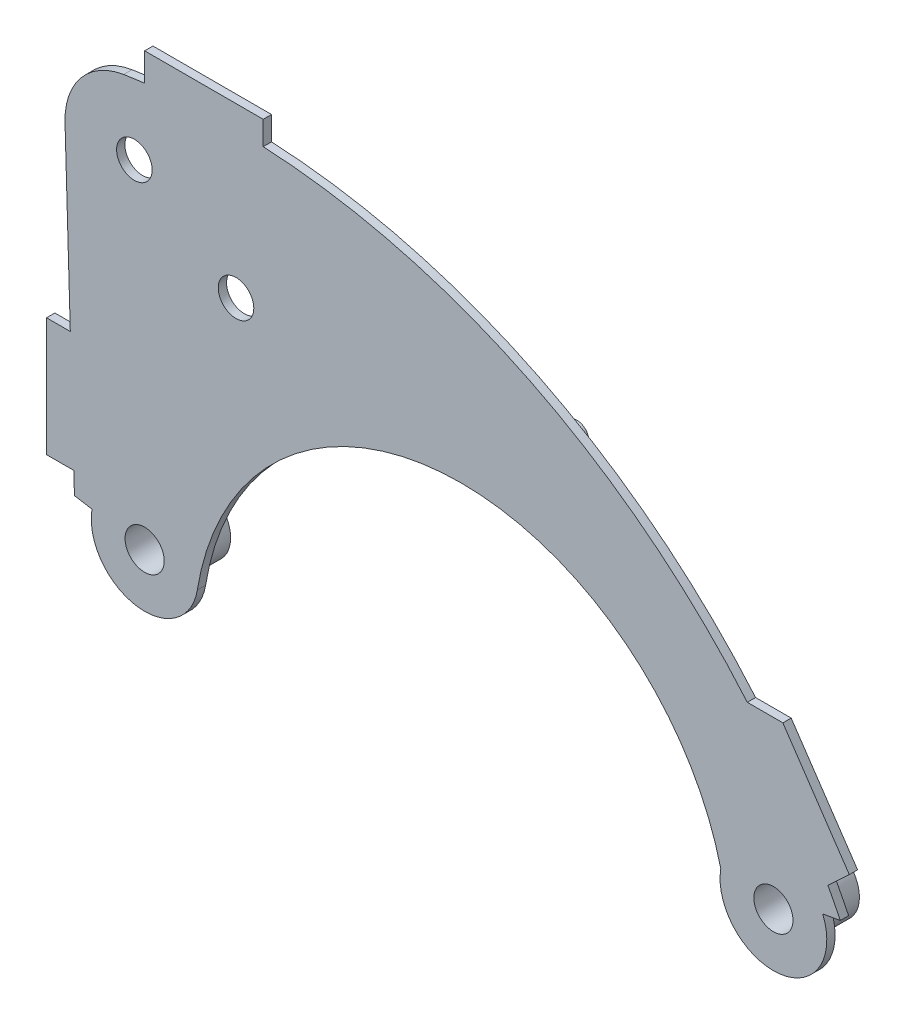
from build123d import *

# Parameters (mm, degrees)
SKETCH1_R            = 16.5
SKETCH1_R_2          = 15
BOSS_EXTRUDE3_DEPTH  = 7
SKETCH2_R            = 27.5
SKETCH2_R_2          = 16.5
BOSS_EXTRUDE4_DEPTH  = 45
SKETCH4_R            = 10
SKETCH4_R_2          = 13
BOSS_EXTRUDE10_DEPTH = 20
BOSS_EXTRUDE11_DEPTH = 7
BOSS_EXTRUDE12_DEPTH = 7
BOSS_EXTRUDE13_DEPTH = 7


with BuildPart() as part:
    # Sketch1 → Boss-Extrude3 (new body)
    with BuildSketch(Plane.XY):
        with BuildLine():
            Line((-322.811275448, 54.020092964), (-308.016991909, 51.544375984))
            ThreePointArc((-308.016991909, 51.544375984), (-297.979605272, 15.041649319), (-263.634141291, -0.882774953))
            Line((-263.634141291, -0.882774953), (-262.985194212, -0.878095462))
            ThreePointArc((-262.985194212, -0.878095462), (-234.213459723, 10.066916736), (-219.209238471, 36.945892575))
            ThreePointArc((-219.209238471, 36.945892575), (-5.54789332, 226.171081865), (222.17000985, 54.119057031))
            ThreePointArc((222.17000985, 54.119057031), (271.744200091, 2.083431527), (308.115870104, 64.070593748))
            Line((308.115870104, 64.070593748), (322.942948353, 66.658271071))
            ThreePointArc((322.942948353, 66.658271071), (72.802770658, 324.018256719), (-281.327086526, 382.296168148))
            ThreePointArc((-281.327086526, 382.296168148), (-317.291599122, 361.87304371), (-330.761322011, 322.769121357))
            Line((-330.761322011, 322.769121357), (-322.811275448, 54.020092964))
        make_face()
        with Locations((-263.634141291, 44.117225047)):
            Circle(SKETCH1_R, mode=Mode.SUBTRACT)
        with Locations((266.5683015, 46.784774614)):
            Circle(SKETCH1_R, mode=Mode.SUBTRACT)
        with Locations((-186.584414745, 266.470160007)):
            Circle(SKETCH1_R_2, mode=Mode.SUBTRACT)
        with Locations((-272.286901184, 324.498892702)):
            Circle(SKETCH1_R_2, mode=Mode.SUBTRACT)
    extrude(amount=BOSS_EXTRUDE3_DEPTH)

    # Sketch2 → Boss-Extrude4 (add)
    with BuildSketch(Plane.XY.offset(7)):
        with Locations((-263.634141291, 44.117225047)):
            Circle(SKETCH2_R)
        with Locations((-263.634141291, 44.117225047)):
            Circle(SKETCH2_R_2, mode=Mode.SUBTRACT)
        with Locations((266.5683015, 46.784774614)):
            Circle(SKETCH2_R)
        with Locations((266.5683015, 46.784774614)):
            Circle(SKETCH2_R_2, mode=Mode.SUBTRACT)
    extrude(amount=-BOSS_EXTRUDE4_DEPTH)

    # Sketch4 → Boss-Extrude10 (add)
    with BuildSketch(Plane(origin=(0, 0, 0), x_dir=(-1, 0, 0), z_dir=(0, 0, -1))):
        with Locations((-73.977350909, 283.959387959)):
            Circle(SKETCH4_R)
        with Locations((77.070617643, 306.793749247)):
            Circle(SKETCH4_R)
        with Locations((0, 304.731170723)):
            Circle(SKETCH4_R_2)
    extrude(amount=BOSS_EXTRUDE10_DEPTH)

    # Sketch6 → Boss-Extrude11 (add)
    with BuildSketch(Plane(origin=(0, 0, 0), x_dir=(-1, 0, 0), z_dir=(0, 0, -1))):
        Polygon((-244.528320181, 186.784774614), (-312.13241104, 86.784774614), (-330.534833245, 103.93991663), (-274.528320181, 186.784774614), align=None)
    extrude(amount=-BOSS_EXTRUDE11_DEPTH)

    # Sketch9 → Boss-Extrude12 (add)
    with BuildSketch(Plane(origin=(0, 0, 0), x_dir=(-1, 0, 0), z_dir=(0, 0, -1))):
        Polygon((326.306060919, 172.160306644), (346.306060919, 172.160306644), (346.306060919, 72.160306644), (323.347893363, 72.160306644), align=None)
    extrude(amount=-BOSS_EXTRUDE12_DEPTH)

    # Sketch10 → Boss-Extrude13 (add)
    with BuildSketch(Plane(origin=(0, 0, 0), x_dir=(-1, 0, 0), z_dir=(0, 0, -1))):
        Polygon((163.634141291, 388.447481806), (163.634141291, 408.447481806), (263.634141291, 408.447481806), (263.634141291, 384.173082441), align=None)
    extrude(amount=-BOSS_EXTRUDE13_DEPTH)


solid = part.part
